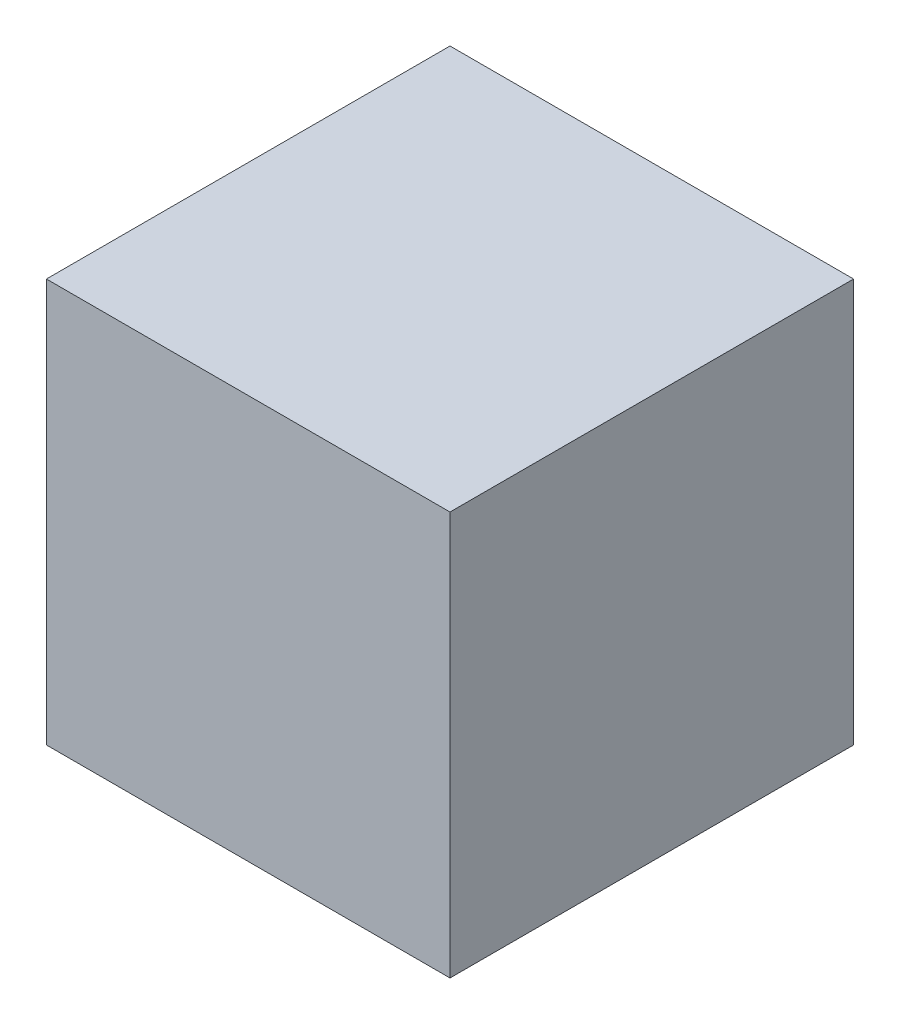
from build123d import *

# Parameters (mm, degrees)
SKETCH1_W           = 100
SKETCH1_H           = 100
BOSS_EXTRUDE1_DEPTH = 100


with BuildPart() as part:
    # Sketch1 → Boss-Extrude1 (new body)
    with BuildSketch(Plane.XY):
        Rectangle(SKETCH1_W, SKETCH1_H)
    extrude(amount=BOSS_EXTRUDE1_DEPTH)


solid = part.part
